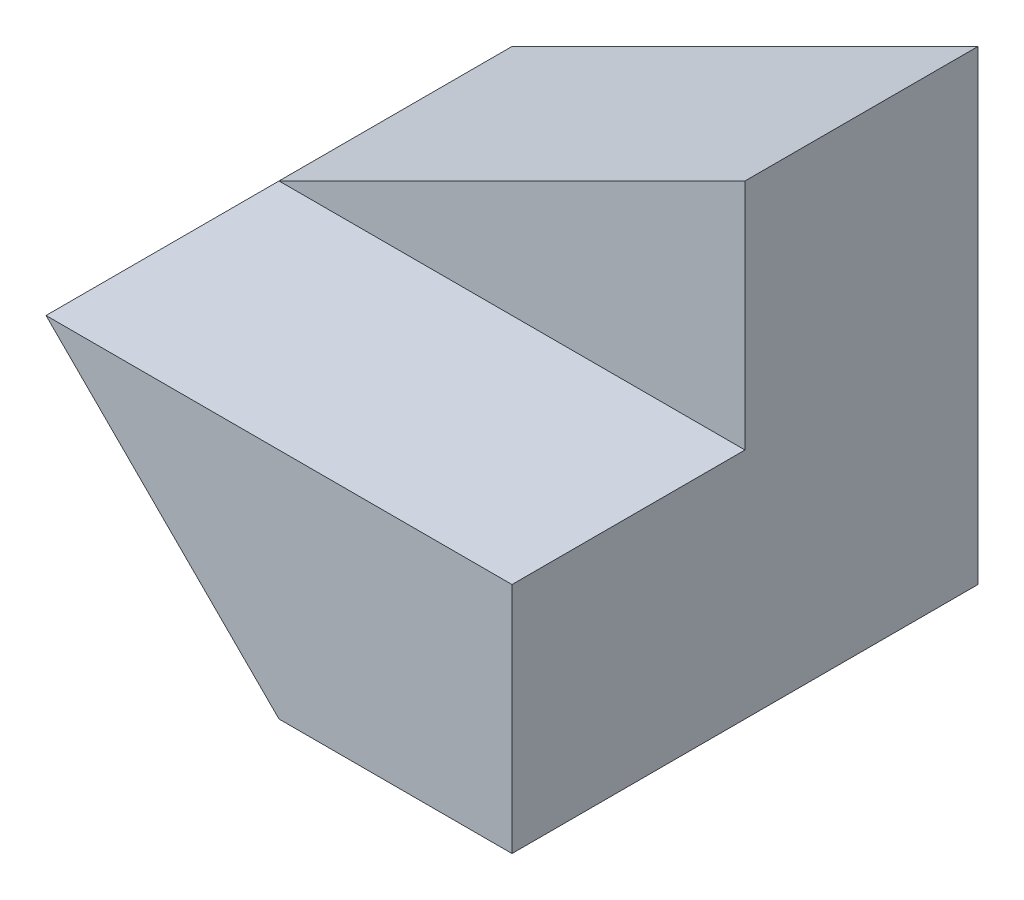
from build123d import *

# Parameters (mm, degrees)
SKETCH1_W           = 40
SKETCH1_H           = 40
BOSS_EXTRUDE1_DEPTH = 40
CUT_EXTRUDE1_DEPTH  = 40
SKETCH3_W           = 20
SKETCH3_H           = 20
CUT_EXTRUDE2_DEPTH  = 40
CUT_EXTRUDE4_DEPTH  = 20


with BuildPart() as part:
    # Sketch1 → Boss-Extrude1 (new body)
    with BuildSketch(Plane.XY):
        with Locations((20, 20)):
            Rectangle(SKETCH1_W, SKETCH1_H)
    extrude(amount=BOSS_EXTRUDE1_DEPTH)

    # Sketch2 → Cut-Extrude1 (cut)
    with BuildSketch(Plane.XY.offset(40)):
        Polygon((40, 40), (0, 40), (0, 20), align=None)
    extrude(amount=-CUT_EXTRUDE1_DEPTH, mode=Mode.SUBTRACT)

    # Sketch3 → Cut-Extrude2 (cut)
    with BuildSketch(Plane(origin=(40, 0, 0), x_dir=(0, 0, -1), z_dir=(1, 0, 0))):
        with Locations((-30, 30)):
            Rectangle(SKETCH3_W, SKETCH3_H)
    extrude(amount=-CUT_EXTRUDE2_DEPTH, mode=Mode.SUBTRACT)

    # Sketch4 → Cut-Extrude4 (cut)
    with BuildSketch(Plane.XY.offset(40)):
        Polygon((0, 20), (20, 0), (0, 0), align=None)
    extrude(amount=-CUT_EXTRUDE4_DEPTH, mode=Mode.SUBTRACT)


solid = part.part
